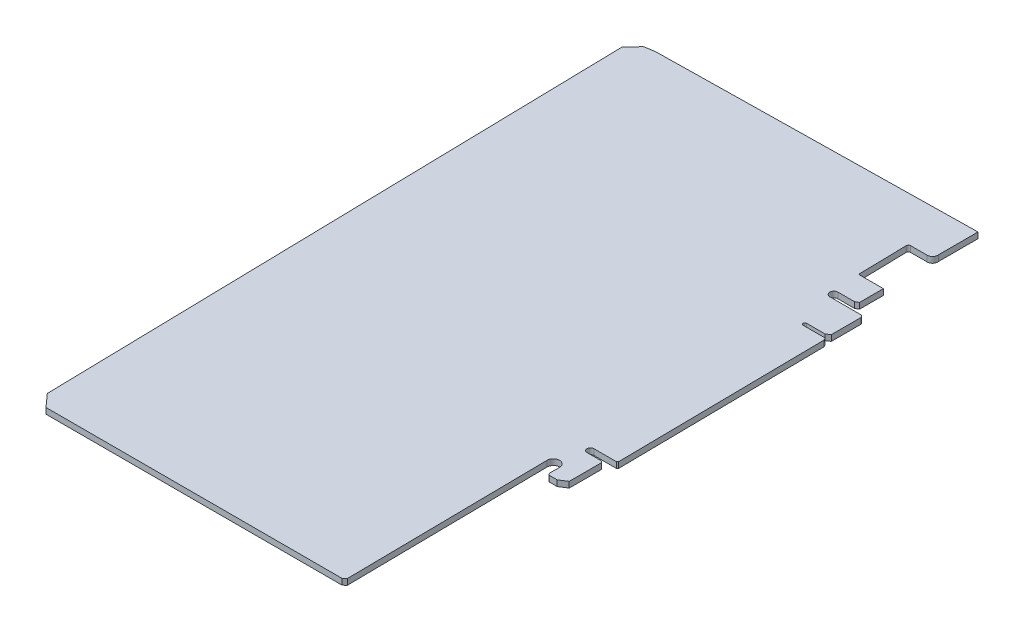
from build123d import *

# Parameters (mm, degrees)
BOSS_EXTRUDE1_DEPTH = 2


with BuildPart() as part:
    # Sketch2 → Boss-Extrude1 (new body)
    with BuildSketch(Plane(origin=(0, 0, 0), x_dir=(1, 0, 0), z_dir=(0, 1, 0))):
        with BuildLine():
            Line((377.810759056, 1640.360670751), (377.762780786, 1638.727684223))
            Line((377.762780786, 1638.727684223), (377.762780786, 1637.032768164))
            ThreePointArc((377.762780786, 1637.032768164), (377.973133338, 1636.52493218), (378.480969321, 1636.314579628))
            Line((378.480969321, 1636.314579628), (381.034322317, 1636.314579628))
            Line((381.034322317, 1636.314579628), (383.53259373, 1637.921344077))
            Line((383.53259373, 1637.921344077), (383.53259373, 1648.93129383))
            Line((383.53259373, 1648.93129383), (382.997065463, 1649.428721271))
            Line((382.997065463, 1649.428721271), (378.071384282, 1649.428721271))
            ThreePointArc((378.071384282, 1649.428721271), (376.912121238, 1650.587984315), (378.071384282, 1651.747247359))
            Line((378.071384282, 1651.747247359), (385.733950351, 1651.747247359))
            Line((385.733950351, 1651.747247359), (386.145150231, 1652.107387132))
            Line((386.145150231, 1652.107387132), (385.251957701, 1722.695235293))
            ThreePointArc((385.251957701, 1722.695235293), (385.107061178, 1723.280508889), (384.717360317, 1723.740588689))
            Line((384.717360317, 1723.740588689), (377.294522639, 1723.740588689))
            ThreePointArc((377.294522639, 1723.740588689), (376.703471551, 1724.331639778), (377.294522639, 1724.922690866))
            Line((377.294522639, 1724.922690866), (383.5733207, 1724.922690866))
            Line((383.5733207, 1724.922690866), (384.893964101, 1725.772063299))
            Line((384.893964101, 1725.772063299), (384.893964101, 1735.694301181))
            ThreePointArc((384.893964101, 1735.694301181), (384.606449822, 1736.388422052), (383.912328951, 1736.675936331))
            Line((383.912328951, 1736.675936331), (373.489641238, 1736.675936331))
            ThreePointArc((373.489641238, 1736.675936331), (372.1028909, 1738.062686668), (373.489641238, 1739.449437006))
            Line((373.489641238, 1739.449437006), (379.048025738, 1739.449437006))
            Line((379.048025738, 1739.449437006), (380.205497535, 1740.065323077))
            Line((380.205497535, 1740.065323077), (380.205497535, 1748.201358299))
            Line((380.205497535, 1748.201358299), (371.764667819, 1748.201358299))
            Line((371.764667819, 1748.201358299), (371.408873695, 1764.738317132))
            ThreePointArc((371.408873695, 1764.738317132), (371.619067882, 1765.278343177), (372.149553695, 1765.511569521))
            Line((372.149553695, 1765.511569521), (377.810759056, 1765.511569521))
            ThreePointArc((377.810759056, 1765.511569521), (379.185604537, 1766.148142401), (379.589611464, 1767.608349076))
            Line((379.589611464, 1767.608349076), (379.589611464, 1781.024075112))
            Line((379.589611464, 1781.024075112), (271.404811714, 1779.291132304))
            Line((271.404811714, 1779.291132304), (267.990517204, 1778.686872698))
            Line((267.990517204, 1778.686872698), (264.479907812, 1774.907365565))
            Line((264.479907812, 1774.907365565), (268.781456477, 1574.975639595))
            Line((268.781456477, 1574.975639595), (272.687420737, 1570.633405031))
            Line((272.687420737, 1570.633405031), (373.489641238, 1570.633405031))
            Line((373.489641238, 1570.633405031), (374.425169749, 1571.4749397))
            Line((374.425169749, 1571.4749397), (373.553861857, 1640.333273274))
            ThreePointArc((373.553861857, 1640.333273274), (375.668526286, 1642.488694532), (377.810759056, 1640.360670751))
        make_face()
    extrude(amount=BOSS_EXTRUDE1_DEPTH)


solid = part.part
